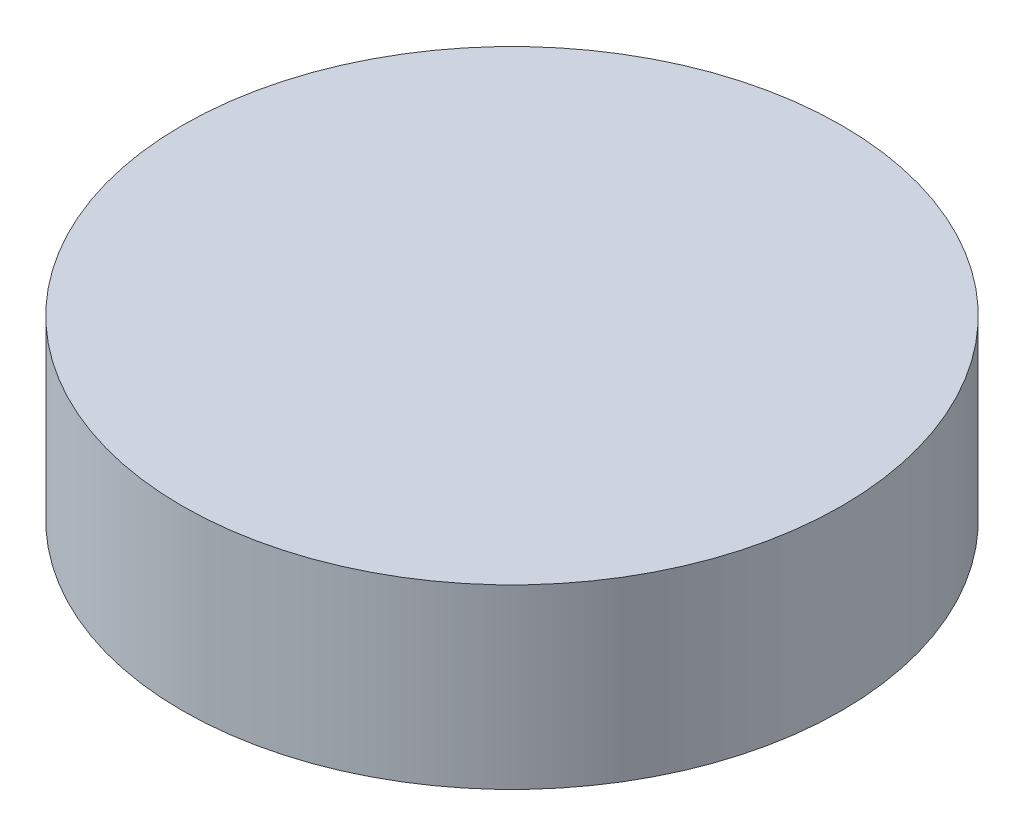
from build123d import *

# Parameters (mm, degrees)
SKETCH1_R                = 21.4
SKETCH1_R_2              = 1.55
BOSS_EXTRUDE1_DEPTH      = 11.5
BOSS_EXTRUDE2_DEPTH      = 11.5
BOSS_EXTRUDE2_DEPTH_BACK = 5
SKETCH1_3_R              = 1.55


with BuildPart() as part:
    # Sketch1 → Boss-Extrude1 (new body)
    with BuildSketch(Plane(origin=(0, 0, 0), x_dir=(1, 0, 0), z_dir=(0, 1, 0))):
        Circle(SKETCH1_R)
        with Locations((-8.6, 0)):
            Circle(SKETCH1_R_2, mode=Mode.SUBTRACT)
        with Locations((8.6, 0)):
            Circle(SKETCH1_R_2, mode=Mode.SUBTRACT)
    extrude(amount=BOSS_EXTRUDE1_DEPTH)

    # Sketch1_3 → Boss-Extrude2 (add, two sides: drawn at the far end of the back side and taken through both)
    with BuildSketch(Plane(origin=(0, 0, 0), x_dir=(1, 0, 0), z_dir=(0, 1, 0)).offset(-BOSS_EXTRUDE2_DEPTH_BACK)):
        with Locations((8.6, 0)):
            Circle(SKETCH1_3_R)
        with Locations((-8.6, 0)):
            Circle(SKETCH1_3_R)
    extrude(amount=BOSS_EXTRUDE2_DEPTH + BOSS_EXTRUDE2_DEPTH_BACK)


solid = part.part
